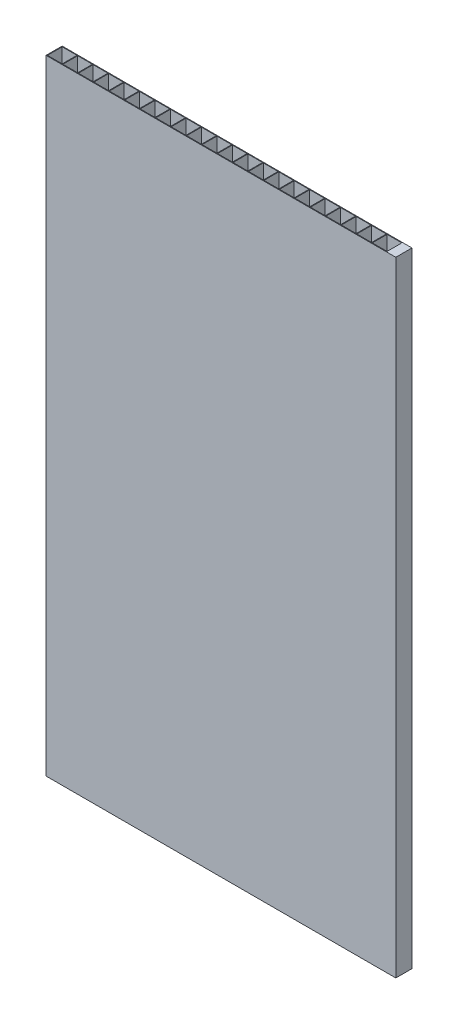
from build123d import *

# Parameters (mm, degrees)
SKETCH1_W           = 130
SKETCH1_H           = 6
SKETCH1_W_2         = 5.5
SKETCH1_H_2         = 5.5
BOSS_EXTRUDE1_DEPTH = 232


with BuildPart() as part:
    # Sketch1 → Boss-Extrude1 (new body)
    with BuildSketch(Plane(origin=(0, 0, 0), x_dir=(1, 0, 0), z_dir=(0, 1, 0))):
        with Locations((65, 3)):
            Rectangle(SKETCH1_W, SKETCH1_H)
        with Locations((8.75, 3)):
            Rectangle(SKETCH1_W_2, SKETCH1_H_2, mode=Mode.SUBTRACT)
        with Locations((3, 3)):
            Rectangle(SKETCH1_W_2, SKETCH1_H_2, mode=Mode.SUBTRACT)
        with Locations((14.5, 3)):
            Rectangle(SKETCH1_W_2, SKETCH1_H_2, mode=Mode.SUBTRACT)
        with Locations((20.25, 3)):
            Rectangle(SKETCH1_W_2, SKETCH1_H_2, mode=Mode.SUBTRACT)
        with Locations((26, 3)):
            Rectangle(SKETCH1_W_2, SKETCH1_H_2, mode=Mode.SUBTRACT)
        with Locations((31.75, 3)):
            Rectangle(SKETCH1_W_2, SKETCH1_H_2, mode=Mode.SUBTRACT)
        with Locations((37.5, 3)):
            Rectangle(SKETCH1_W_2, SKETCH1_H_2, mode=Mode.SUBTRACT)
        with Locations((43.25, 3)):
            Rectangle(SKETCH1_W_2, SKETCH1_H_2, mode=Mode.SUBTRACT)
        with Locations((49, 3)):
            Rectangle(SKETCH1_W_2, SKETCH1_H_2, mode=Mode.SUBTRACT)
        with Locations((54.75, 3)):
            Rectangle(SKETCH1_W_2, SKETCH1_H_2, mode=Mode.SUBTRACT)
        with Locations((60.5, 3)):
            Rectangle(SKETCH1_W_2, SKETCH1_H_2, mode=Mode.SUBTRACT)
        with Locations((66.25, 3)):
            Rectangle(SKETCH1_W_2, SKETCH1_H_2, mode=Mode.SUBTRACT)
        with Locations((72, 3)):
            Rectangle(SKETCH1_W_2, SKETCH1_H_2, mode=Mode.SUBTRACT)
        with Locations((77.75, 3)):
            Rectangle(SKETCH1_W_2, SKETCH1_H_2, mode=Mode.SUBTRACT)
        with Locations((83.5, 3)):
            Rectangle(SKETCH1_W_2, SKETCH1_H_2, mode=Mode.SUBTRACT)
        with Locations((89.25, 3)):
            Rectangle(SKETCH1_W_2, SKETCH1_H_2, mode=Mode.SUBTRACT)
        with Locations((95, 3)):
            Rectangle(SKETCH1_W_2, SKETCH1_H_2, mode=Mode.SUBTRACT)
        with Locations((100.75, 3)):
            Rectangle(SKETCH1_W_2, SKETCH1_H_2, mode=Mode.SUBTRACT)
        with Locations((106.5, 3)):
            Rectangle(SKETCH1_W_2, SKETCH1_H_2, mode=Mode.SUBTRACT)
        with Locations((112.25, 3)):
            Rectangle(SKETCH1_W_2, SKETCH1_H_2, mode=Mode.SUBTRACT)
        with Locations((118, 3)):
            Rectangle(SKETCH1_W_2, SKETCH1_H_2, mode=Mode.SUBTRACT)
        with Locations((123.75, 3)):
            Rectangle(SKETCH1_W_2, SKETCH1_H_2, mode=Mode.SUBTRACT)
    extrude(amount=BOSS_EXTRUDE1_DEPTH)


solid = part.part
